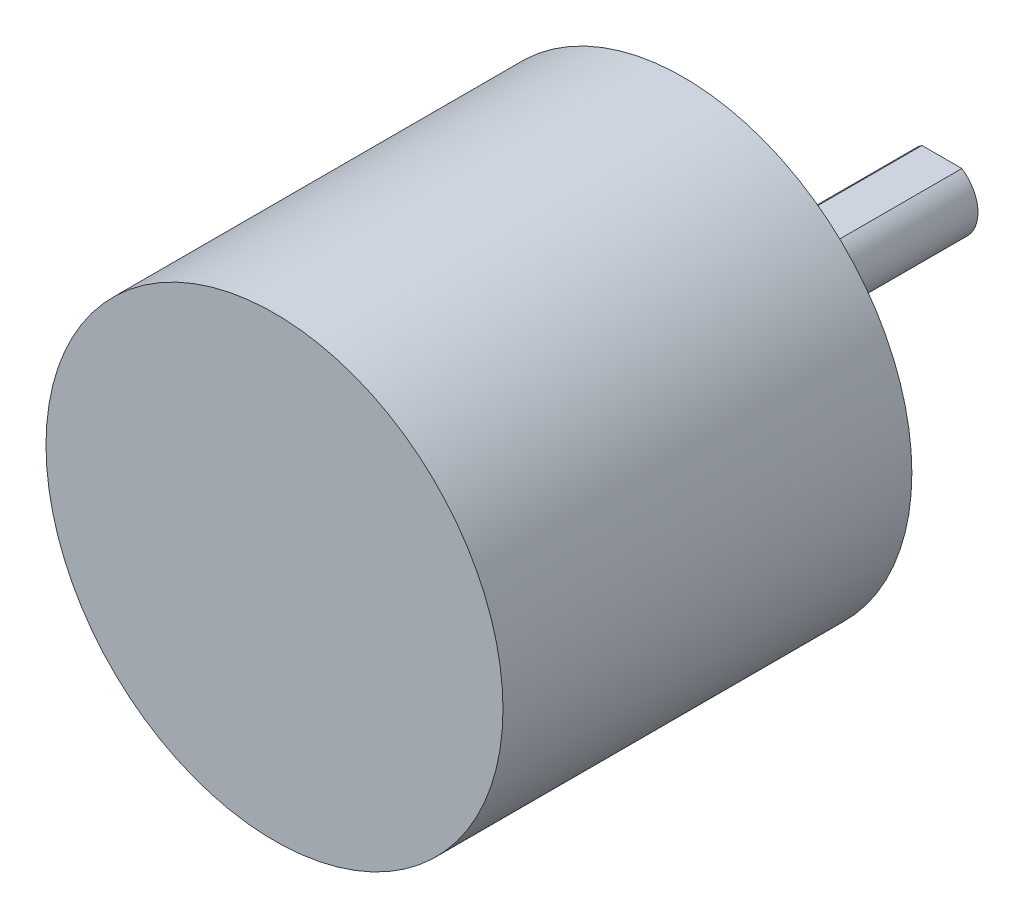
from build123d import *

# Parameters (mm, degrees)
SKETCH_1_R          = 19
EXTRUDE_1_DEPTH     = 34
SKETCH_2_R          = 10
EXTRUDE_2_DEPTH     = 5
SKETCH_3_R          = 4
EXTRUDE_3_DEPTH     = 1
SKETCH_4_R          = 3
EXTRUDE_4_DEPTH     = 15.5
CUT_EXTRUDE_2_DEPTH = 12
SKETCH_7_R          = 1.5
CUT_EXTRUDE_3_DEPTH = 6


with BuildPart() as part:
    # 草图1 → 凸台-拉伸1 (new body)
    with BuildSketch(Plane.XY):
        Circle(SKETCH_1_R)
    extrude(amount=EXTRUDE_1_DEPTH)

    # 草图2 → 凸台-拉伸2 (add)
    with BuildSketch(Plane(origin=(0, 0, 0), x_dir=(-1, 0, 0), z_dir=(0, 0, -1))):
        Circle(SKETCH_2_R)
    extrude(amount=EXTRUDE_2_DEPTH)

    # 草图3 → 凸台-拉伸3 (add)
    with BuildSketch(Plane(origin=(0, 0, -5), x_dir=(-1, 0, 0), z_dir=(0, 0, -1))):
        Circle(SKETCH_3_R)
    extrude(amount=EXTRUDE_3_DEPTH)

    # 草图4 → 凸台-拉伸4 (add)
    with BuildSketch(Plane(origin=(0, 0, -6), x_dir=(-1, 0, 0), z_dir=(0, 0, -1))):
        Circle(SKETCH_4_R)
    extrude(amount=EXTRUDE_4_DEPTH)

    # 草图5 → 切除-拉伸2 (cut)
    with BuildSketch(Plane(origin=(0, 0, -21.5), x_dir=(-1, 0, 0), z_dir=(0, 0, -1))):
        with BuildLine():
            ThreePointArc((1.658312395, 2.5), (0.866025404, 2.872281323), (0, 3))
            Line((0, 3), (0, 2.5))
            Line((0, 2.5), (1.658312395, 2.5))
        make_face()
        with BuildLine():
            Line((0, 2.5), (0, 3))
            ThreePointArc((0, 3), (-0.866025404, 2.872281323), (-1.658312395, 2.5))
            Line((-1.658312395, 2.5), (0, 2.5))
        make_face()
    extrude(amount=-CUT_EXTRUDE_2_DEPTH, mode=Mode.SUBTRACT)

    # 草图7 → 切除-拉伸3 (cut)
    with BuildSketch(Plane(origin=(0, 0, 0), x_dir=(-1, 0, 0), z_dir=(0, 0, -1))):
        with Locations((0, 15)):
            Circle(SKETCH_7_R)
        with Locations((-12.990381057, -7.5)):
            Circle(SKETCH_7_R)
        with Locations((12.990381057, -7.5)):
            Circle(SKETCH_7_R)
    extrude(amount=-CUT_EXTRUDE_3_DEPTH, mode=Mode.SUBTRACT)


solid = part.part
